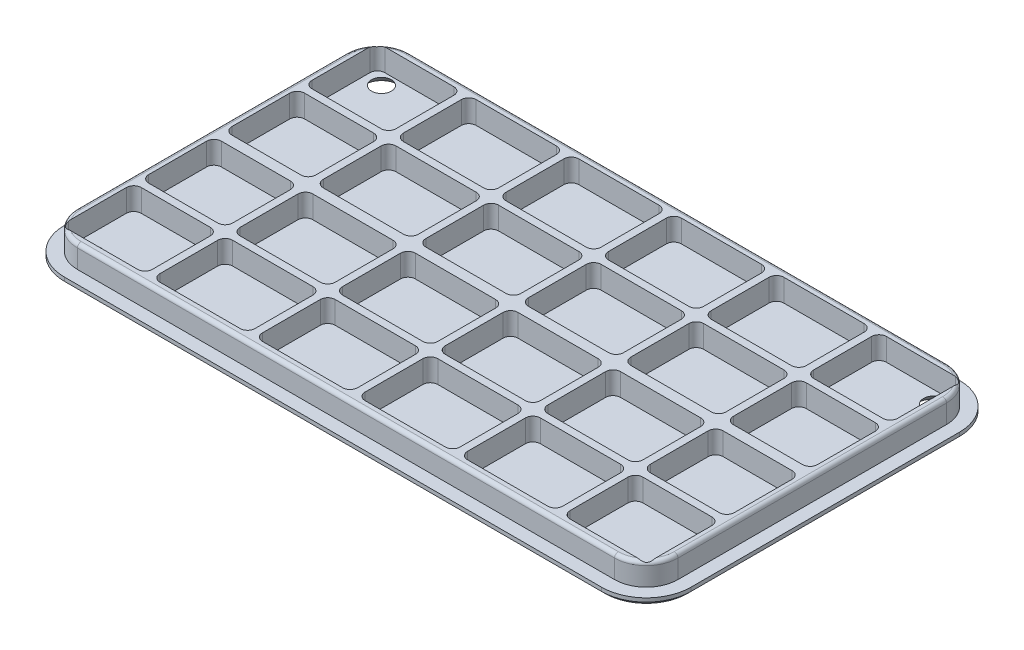
from build123d import *

# Parameters (mm, degrees)
BOSS_EXTRUDE1_DEPTH  = 1
CHAMFER1_SIZE        = 0.5
BOSS_EXTRUDE2_DEPTH  = 3
FILLET2_R            = 0.3
FILLET1_R            = 0.5
CUT_EXTRUDE1_DEPTH   = 3
CUT_EXTRUDE2_DEPTH   = 3
CUT_EXTRUDE3_DEPTH   = 3
CUT_EXTRUDE4_DEPTH   = 3
CUT_EXTRUDE6_DEPTH   = 3
CUT_EXTRUDE7_DEPTH   = 3
MIRROR8_COPY_1_DEPTH = 3
MIRROR8_COPY_2_DEPTH = 3
MIRROR8_COPY_3_DEPTH = 3
MIRROR8_COPY_4_DEPTH = 3
MIRROR8_COPY_5_DEPTH = 3
MIRROR8_COPY_6_DEPTH = 3


with BuildPart() as part:
    # Sketch1 → Boss-Extrude1 (new body)
    with BuildSketch(Plane(origin=(0, 0, 0), x_dir=(1, 0, 0), z_dir=(0, 1, 0))):
        with BuildLine():
            Line((-36, 24), (36, 24))
            ThreePointArc((36, 24), (40.242640687, 22.242640687), (42, 18))
            Line((42, 18), (42, -18))
            ThreePointArc((42, -18), (40.242640687, -22.242640687), (36, -24))
            Line((36, -24), (-36, -24))
            ThreePointArc((-36, -24), (-40.242640687, -22.242640687), (-42, -18))
            Line((-42, -18), (-42, 18))
            ThreePointArc((-42, 18), (-40.242640687, 22.242640687), (-36, 24))
        make_face()
    extrude(amount=BOSS_EXTRUDE1_DEPTH)

    # Chamfer1
    chamfer1_edges = [part.edges().sort_by_distance(p)[0] for p in [
        (0, 0, 24),
        (-40.242640687, 0, 22.242640687),
        (-42, 0, 0),
        (-40.242640687, 0, -22.242640687),
        (0, 0, -24),
        (40.242640687, 0, -22.242640687),
        (42, 0, 0),
        (40.242640687, 0, 22.242640687),
    ]]
    chamfer(chamfer1_edges, length=CHAMFER1_SIZE)

    # Sketch2 → Boss-Extrude2 (add)
    with BuildSketch(Plane(origin=(0, 1, 0), x_dir=(1, 0, 0), z_dir=(0, 1, 0))):
        with BuildLine():
            Line((-36, 22.25), (36, 22.25))
            ThreePointArc((36, 22.25), (39.00520382, 21.00520382), (40.25, 18))
            Line((40.25, 18), (40.25, -18))
            ThreePointArc((40.25, -18), (39.00520382, -21.00520382), (36, -22.25))
            Line((36, -22.25), (-36, -22.25))
            ThreePointArc((-36, -22.25), (-39.00520382, -21.00520382), (-40.25, -18))
            Line((-40.25, -18), (-40.25, 18))
            ThreePointArc((-40.25, 18), (-39.00520382, 21.00520382), (-36, 22.25))
        make_face()
    extrude(amount=BOSS_EXTRUDE2_DEPTH)

    # Sketch14 → Hole2 (revolve, cut)
    with BuildSketch(Plane(origin=(37, 0, -19.5), x_dir=(0, 0, -1), z_dir=(1, 0, 0))):
        Polygon((0, 0), (0, 4.751075774), (1.25, 4), (1.25, 1.092849987), (2.2, 0), align=None)
    hole2 = revolve(axis=Axis((37, -14.308894879, -19.5), (0, 1, 0)), mode=Mode.SUBTRACT)

    # Fillet2
    fillet2_edges = [part.edges().sort_by_distance(p)[0] for p in [
        (37, 0, -17.3),
        (37, 1.092849987, -18.25),
    ]]
    fillet(fillet2_edges, radius=FILLET2_R)

    # Mirror9: Hole2 across plane
    add(hole2.mirror(Plane(origin=(0, 0, 0), x_dir=(0, 0, 1), z_dir=(1, 0, 0))), mode=Mode.SUBTRACT)

    # Mirror10: Hole2 across plane
    add(hole2.mirror(Plane.XY), mode=Mode.SUBTRACT)

    # Mirror10 copy 1 sketch → Mirror10 copy 1 (revolve, cut)
    with BuildSketch(Plane(origin=(-37, 0, 19.5), x_dir=(0, 0, 1), z_dir=(-1, 0, 0))):
        Polygon((0, 0), (0, 4.751075774), (1.25, 4), (1.25, 1.092849987), (2.2, 0), align=None)
    revolve(axis=Axis((-37, -14.308894879, 19.5), (0, 1, 0)), mode=Mode.SUBTRACT)

    # Fillet1
    fillet1_edges = [part.edges().sort_by_distance(p)[0] for p in [
        (-39.00520382, 4, -21.00520382),
        (-40.25, 4, 0),
        (-39.00520382, 4, 21.00520382),
        (0, 4, 22.25),
        (39.00520382, 4, 21.00520382),
        (40.25, 4, 0),
        (39.00520382, 4, -21.00520382),
        (0, 4, -22.25),
    ]]
    fillet(fillet1_edges, radius=FILLET1_R)

    # Sketch3 → Cut-Extrude1 (cut)
    with BuildSketch(Plane(origin=(0, 4, 0), x_dir=(1, 0, 0), z_dir=(0, 1, 0))):
        with BuildLine():
            Line((-38.25, 21.2), (-29, 21.2))
            ThreePointArc((-29, 21.2), (-28.292893219, 20.907106781), (-28, 20.2))
            Line((-28, 20.2), (-28, 12.45))
            ThreePointArc((-28, 12.45), (-28.292893219, 11.742893219), (-29, 11.45))
            Line((-29, 11.45), (-38.25, 11.45))
            ThreePointArc((-38.25, 11.45), (-38.957106781, 11.742893219), (-39.25, 12.45))
            Line((-39.25, 12.45), (-39.25, 20.2))
            ThreePointArc((-39.25, 20.2), (-38.957106781, 20.907106781), (-38.25, 21.2))
        make_face()
    cut_extrude1 = extrude(amount=-CUT_EXTRUDE1_DEPTH, mode=Mode.SUBTRACT)

    # Sketch5 → Cut-Extrude2 (cut)
    with BuildSketch(Plane(origin=(0, 4, 0), x_dir=(1, 0, 0), z_dir=(0, 1, 0))):
        with BuildLine():
            Line((-38.25, 10.45), (-29, 10.45))
            ThreePointArc((-29, 10.45), (-28.292893219, 10.157106781), (-28, 9.45))
            Line((-28, 9.45), (-28, 1.7))
            ThreePointArc((-28, 1.7), (-28.292893219, 0.992893219), (-29, 0.7))
            Line((-29, 0.7), (-38.25, 0.7))
            ThreePointArc((-38.25, 0.7), (-38.957106781, 0.992893219), (-39.25, 1.7))
            Line((-39.25, 1.7), (-39.25, 9.45))
            ThreePointArc((-39.25, 9.45), (-38.957106781, 10.157106781), (-38.25, 10.45))
        make_face()
    cut_extrude2 = extrude(amount=-CUT_EXTRUDE2_DEPTH, mode=Mode.SUBTRACT)

    # Sketch6 → Cut-Extrude3 (cut)
    with BuildSketch(Plane(origin=(0, 4, 0), x_dir=(1, 0, 0), z_dir=(0, 1, 0))):
        with BuildLine():
            Line((-26, 21.2), (-15.25, 21.2))
            ThreePointArc((-15.25, 21.2), (-14.542893219, 20.907106781), (-14.25, 20.2))
            Line((-14.25, 20.2), (-14.25, 12.45))
            ThreePointArc((-14.25, 12.45), (-14.542893219, 11.742893219), (-15.25, 11.45))
            Line((-15.25, 11.45), (-26, 11.45))
            ThreePointArc((-26, 11.45), (-26.707106781, 11.742893219), (-27, 12.45))
            Line((-27, 12.45), (-27, 20.2))
            ThreePointArc((-27, 20.2), (-26.707106781, 20.907106781), (-26, 21.2))
        make_face()
    cut_extrude3 = extrude(amount=-CUT_EXTRUDE3_DEPTH, mode=Mode.SUBTRACT)

    # Sketch7 → Cut-Extrude4 (cut)
    with BuildSketch(Plane(origin=(0, 4, 0), x_dir=(1, 0, 0), z_dir=(0, 1, 0))):
        with BuildLine():
            Line((-26, 10.45), (-15.25, 10.45))
            ThreePointArc((-15.25, 10.45), (-14.542893219, 10.157106781), (-14.25, 9.45))
            Line((-14.25, 9.45), (-14.25, 1.7))
            ThreePointArc((-14.25, 1.7), (-14.542893219, 0.992893219), (-15.25, 0.7))
            Line((-15.25, 0.7), (-26, 0.7))
            ThreePointArc((-26, 0.7), (-26.707106781, 0.992893219), (-27, 1.7))
            Line((-27, 1.7), (-27, 9.45))
            ThreePointArc((-27, 9.45), (-26.707106781, 10.157106781), (-26, 10.45))
        make_face()
    cut_extrude4 = extrude(amount=-CUT_EXTRUDE4_DEPTH, mode=Mode.SUBTRACT)

    # Sketch9 → Cut-Extrude6 (cut)
    with BuildSketch(Plane(origin=(0, 4, 0), x_dir=(1, 0, 0), z_dir=(0, 1, 0))):
        with BuildLine():
            Line((-12.25, 21.2), (-1.5, 21.2))
            ThreePointArc((-1.5, 21.2), (-0.792893219, 20.907106781), (-0.5, 20.2))
            Line((-0.5, 20.2), (-0.5, 12.45))
            ThreePointArc((-0.5, 12.45), (-0.792893219, 11.742893219), (-1.5, 11.45))
            Line((-1.5, 11.45), (-12.25, 11.45))
            ThreePointArc((-12.25, 11.45), (-12.957106781, 11.742893219), (-13.25, 12.45))
            Line((-13.25, 12.45), (-13.25, 20.2))
            ThreePointArc((-13.25, 20.2), (-12.957106781, 20.907106781), (-12.25, 21.2))
        make_face()
    cut_extrude6 = extrude(amount=-CUT_EXTRUDE6_DEPTH, mode=Mode.SUBTRACT)

    # Sketch10 → Cut-Extrude7 (cut)
    with BuildSketch(Plane(origin=(0, 4, 0), x_dir=(1, 0, 0), z_dir=(0, 1, 0))):
        with BuildLine():
            Line((-12.25, 10.45), (-1.5, 10.45))
            ThreePointArc((-1.5, 10.45), (-0.792893219, 10.157106781), (-0.5, 9.45))
            Line((-0.5, 9.45), (-0.5, 1.7))
            ThreePointArc((-0.5, 1.7), (-0.792893219, 0.992893219), (-1.5, 0.7))
            Line((-1.5, 0.7), (-12.25, 0.7))
            ThreePointArc((-12.25, 0.7), (-12.957106781, 0.992893219), (-13.25, 1.7))
            Line((-13.25, 1.7), (-13.25, 9.45))
            ThreePointArc((-13.25, 9.45), (-12.957106781, 10.157106781), (-12.25, 10.45))
        make_face()
    cut_extrude7 = extrude(amount=-CUT_EXTRUDE7_DEPTH, mode=Mode.SUBTRACT)

    # Mirror7: Cut-Extrude1, Cut-Extrude2, Cut-Extrude3, Cut-Extrude4, Cut-Extrude6, Cut-Extrude7 across plane
    add(cut_extrude1.mirror(Plane(origin=(0, 0, 0), x_dir=(0, 0, 1), z_dir=(1, 0, 0))), mode=Mode.SUBTRACT)
    add(cut_extrude2.mirror(Plane(origin=(0, 0, 0), x_dir=(0, 0, 1), z_dir=(1, 0, 0))), mode=Mode.SUBTRACT)
    add(cut_extrude3.mirror(Plane(origin=(0, 0, 0), x_dir=(0, 0, 1), z_dir=(1, 0, 0))), mode=Mode.SUBTRACT)
    add(cut_extrude4.mirror(Plane(origin=(0, 0, 0), x_dir=(0, 0, 1), z_dir=(1, 0, 0))), mode=Mode.SUBTRACT)
    add(cut_extrude6.mirror(Plane(origin=(0, 0, 0), x_dir=(0, 0, 1), z_dir=(1, 0, 0))), mode=Mode.SUBTRACT)
    add(cut_extrude7.mirror(Plane(origin=(0, 0, 0), x_dir=(0, 0, 1), z_dir=(1, 0, 0))), mode=Mode.SUBTRACT)

    # Mirror8: Cut-Extrude1, Cut-Extrude2, Cut-Extrude3, Cut-Extrude4, Cut-Extrude6, Cut-Extrude7 across plane
    add(cut_extrude1.mirror(Plane.XY), mode=Mode.SUBTRACT)
    add(cut_extrude2.mirror(Plane.XY), mode=Mode.SUBTRACT)
    add(cut_extrude3.mirror(Plane.XY), mode=Mode.SUBTRACT)
    add(cut_extrude4.mirror(Plane.XY), mode=Mode.SUBTRACT)
    add(cut_extrude6.mirror(Plane.XY), mode=Mode.SUBTRACT)
    add(cut_extrude7.mirror(Plane.XY), mode=Mode.SUBTRACT)

    # Mirror8 copy 1 sketch → Mirror8 copy 1 (cut)
    with BuildSketch(Plane(origin=(0, 4, 0), x_dir=(-1, 0, 0), z_dir=(0, 1, 0))):
        with BuildLine():
            Line((-38.25, 21.2), (-29, 21.2))
            ThreePointArc((-29, 21.2), (-28.292893219, 20.907106781), (-28, 20.2))
            Line((-28, 20.2), (-28, 12.45))
            ThreePointArc((-28, 12.45), (-28.292893219, 11.742893219), (-29, 11.45))
            Line((-29, 11.45), (-38.25, 11.45))
            ThreePointArc((-38.25, 11.45), (-38.957106781, 11.742893219), (-39.25, 12.45))
            Line((-39.25, 12.45), (-39.25, 20.2))
            ThreePointArc((-39.25, 20.2), (-38.957106781, 20.907106781), (-38.25, 21.2))
        make_face()
    extrude(amount=-MIRROR8_COPY_1_DEPTH, mode=Mode.SUBTRACT)

    # Mirror8 copy 2 sketch → Mirror8 copy 2 (cut)
    with BuildSketch(Plane(origin=(0, 4, 0), x_dir=(-1, 0, 0), z_dir=(0, 1, 0))):
        with BuildLine():
            Line((-38.25, 10.45), (-29, 10.45))
            ThreePointArc((-29, 10.45), (-28.292893219, 10.157106781), (-28, 9.45))
            Line((-28, 9.45), (-28, 1.7))
            ThreePointArc((-28, 1.7), (-28.292893219, 0.992893219), (-29, 0.7))
            Line((-29, 0.7), (-38.25, 0.7))
            ThreePointArc((-38.25, 0.7), (-38.957106781, 0.992893219), (-39.25, 1.7))
            Line((-39.25, 1.7), (-39.25, 9.45))
            ThreePointArc((-39.25, 9.45), (-38.957106781, 10.157106781), (-38.25, 10.45))
        make_face()
    extrude(amount=-MIRROR8_COPY_2_DEPTH, mode=Mode.SUBTRACT)

    # Mirror8 copy 3 sketch → Mirror8 copy 3 (cut)
    with BuildSketch(Plane(origin=(0, 4, 0), x_dir=(-1, 0, 0), z_dir=(0, 1, 0))):
        with BuildLine():
            Line((-26, 21.2), (-15.25, 21.2))
            ThreePointArc((-15.25, 21.2), (-14.542893219, 20.907106781), (-14.25, 20.2))
            Line((-14.25, 20.2), (-14.25, 12.45))
            ThreePointArc((-14.25, 12.45), (-14.542893219, 11.742893219), (-15.25, 11.45))
            Line((-15.25, 11.45), (-26, 11.45))
            ThreePointArc((-26, 11.45), (-26.707106781, 11.742893219), (-27, 12.45))
            Line((-27, 12.45), (-27, 20.2))
            ThreePointArc((-27, 20.2), (-26.707106781, 20.907106781), (-26, 21.2))
        make_face()
    extrude(amount=-MIRROR8_COPY_3_DEPTH, mode=Mode.SUBTRACT)

    # Mirror8 copy 4 sketch → Mirror8 copy 4 (cut)
    with BuildSketch(Plane(origin=(0, 4, 0), x_dir=(-1, 0, 0), z_dir=(0, 1, 0))):
        with BuildLine():
            Line((-26, 10.45), (-15.25, 10.45))
            ThreePointArc((-15.25, 10.45), (-14.542893219, 10.157106781), (-14.25, 9.45))
            Line((-14.25, 9.45), (-14.25, 1.7))
            ThreePointArc((-14.25, 1.7), (-14.542893219, 0.992893219), (-15.25, 0.7))
            Line((-15.25, 0.7), (-26, 0.7))
            ThreePointArc((-26, 0.7), (-26.707106781, 0.992893219), (-27, 1.7))
            Line((-27, 1.7), (-27, 9.45))
            ThreePointArc((-27, 9.45), (-26.707106781, 10.157106781), (-26, 10.45))
        make_face()
    extrude(amount=-MIRROR8_COPY_4_DEPTH, mode=Mode.SUBTRACT)

    # Mirror8 copy 5 sketch → Mirror8 copy 5 (cut)
    with BuildSketch(Plane(origin=(0, 4, 0), x_dir=(-1, 0, 0), z_dir=(0, 1, 0))):
        with BuildLine():
            Line((-12.25, 21.2), (-1.5, 21.2))
            ThreePointArc((-1.5, 21.2), (-0.792893219, 20.907106781), (-0.5, 20.2))
            Line((-0.5, 20.2), (-0.5, 12.45))
            ThreePointArc((-0.5, 12.45), (-0.792893219, 11.742893219), (-1.5, 11.45))
            Line((-1.5, 11.45), (-12.25, 11.45))
            ThreePointArc((-12.25, 11.45), (-12.957106781, 11.742893219), (-13.25, 12.45))
            Line((-13.25, 12.45), (-13.25, 20.2))
            ThreePointArc((-13.25, 20.2), (-12.957106781, 20.907106781), (-12.25, 21.2))
        make_face()
    extrude(amount=-MIRROR8_COPY_5_DEPTH, mode=Mode.SUBTRACT)

    # Mirror8 copy 6 sketch → Mirror8 copy 6 (cut)
    with BuildSketch(Plane(origin=(0, 4, 0), x_dir=(-1, 0, 0), z_dir=(0, 1, 0))):
        with BuildLine():
            Line((-12.25, 10.45), (-1.5, 10.45))
            ThreePointArc((-1.5, 10.45), (-0.792893219, 10.157106781), (-0.5, 9.45))
            Line((-0.5, 9.45), (-0.5, 1.7))
            ThreePointArc((-0.5, 1.7), (-0.792893219, 0.992893219), (-1.5, 0.7))
            Line((-1.5, 0.7), (-12.25, 0.7))
            ThreePointArc((-12.25, 0.7), (-12.957106781, 0.992893219), (-13.25, 1.7))
            Line((-13.25, 1.7), (-13.25, 9.45))
            ThreePointArc((-13.25, 9.45), (-12.957106781, 10.157106781), (-12.25, 10.45))
        make_face()
    extrude(amount=-MIRROR8_COPY_6_DEPTH, mode=Mode.SUBTRACT)


solid = part.part
